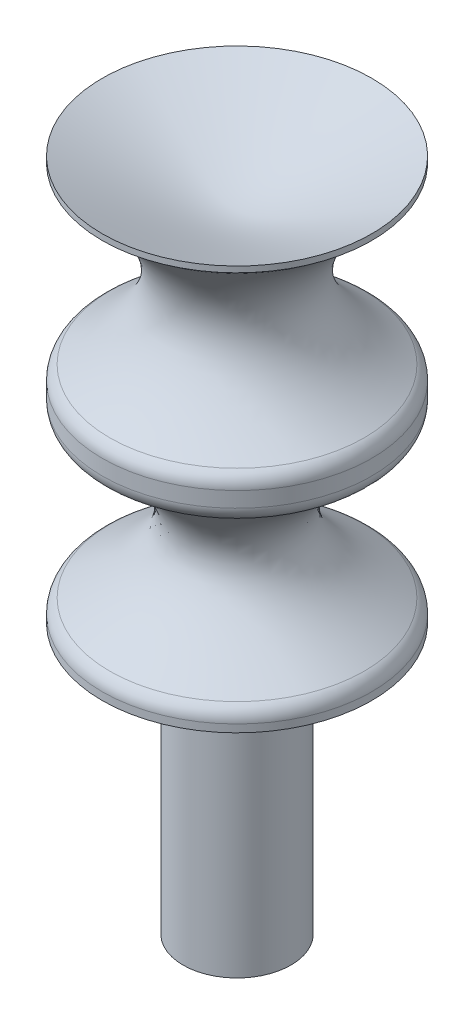
from build123d import *


with BuildPart() as part:
    # Sketch1 → Revolve1 (revolve)
    with BuildSketch(Plane(origin=(0, 0, 0), x_dir=(0, 0, -1), z_dir=(1, 0, 0)), mode=Mode.PRIVATE) as revolve1_sk:
        with BuildLine():
            Line((0, 7.390287575), (0, -9.525))
            Line((0, -9.525), (0, -22.225))
            Line((0, -22.225), (2.54, -22.225))
            Line((2.54, -22.225), (2.54, -9.525))
            Line((2.54, -9.525), (6.35, -9.525))
            Line((6.35, -9.525), (6.35, -9.164266132))
            ThreePointArc((6.35, -9.164266132), (6.25562596, -8.788883222), (5.994945312, -8.502763687))
            add(Edge.make_bspline(
                [(5.994945312, -1.022236313), (0.355054688, -4.7625), (3.175, -6.632631843), (5.994945312, -8.502763687)],
                knots=[0, 0, 0, 0, 1, 1, 1, 1], degree=3))
            ThreePointArc((5.994945312, -1.022236313), (6.25562596, -0.736116778), (6.35, -0.360733868))
            Line((6.35, -0.360733868), (6.35, 0.361159933))
            ThreePointArc((6.35, 0.361159933), (6.255931261, 0.735973481), (5.996021554, 1.021947374))
            add(Edge.make_bspline(
                [(6.35, 9.247051697), (0.182218111, 4.891187644), (5.996021554, 1.021947374)],
                knots=[0, 0, 0, 1, 1, 1], degree=2))
            Line((6.35, 9.247051697), (6.35, 9.525))
            add(Edge.make_bspline(
                [(0, 7.390287575), (1.5875, 7.390287575), (6.35, 9.525)],
                knots=[0, 0, 0, 1, 1, 1], degree=2, weights=[1, 1.414213562, 1]))
        make_face()
    revolve(revolve1_sk.sketch.rotate(Axis((0, -9.525, 0), (0, -1, 0)), 180), axis=Axis((0, -9.525, 0), (0, -1, 0)))


solid = part.part
